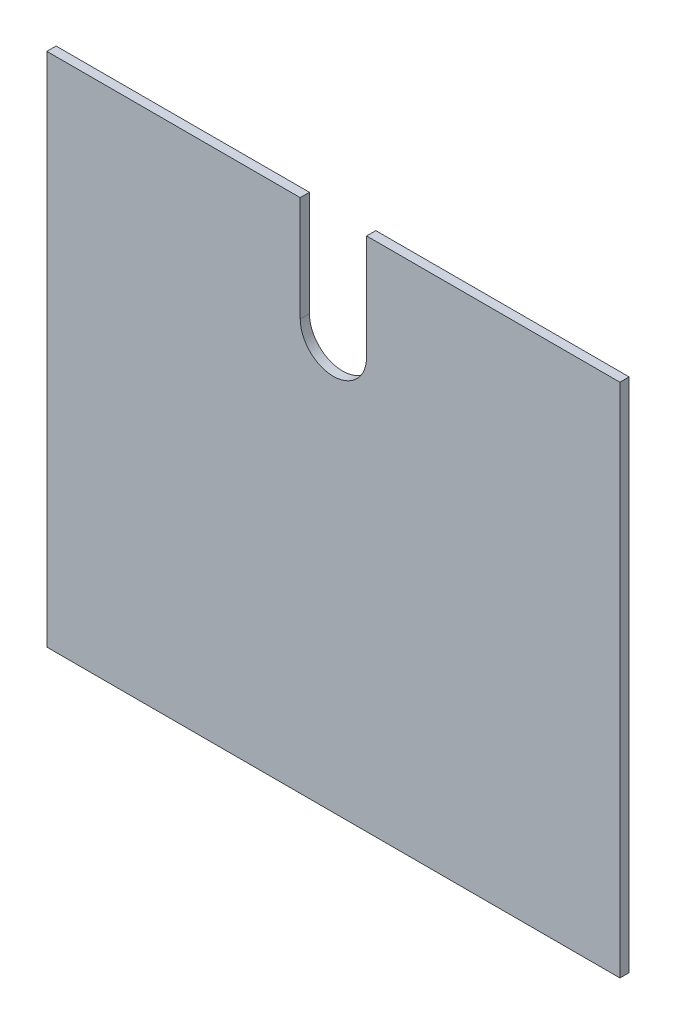
from build123d import *

# Parameters (mm, degrees)
BOSS_EXTRUDE1_DEPTH = 6.35


with BuildPart() as part:
    # Sketch1 → Boss-Extrude1 (new body)
    with BuildSketch(Plane.XY):
        with BuildLine():
            Line((174.625, 355.6), (174.625, 283.21))
            ThreePointArc((174.625, 283.21), (197.485, 260.35), (220.345, 283.21))
            Line((220.345, 283.21), (220.345, 355.6))
            Line((220.345, 355.6), (394.97, 355.6))
            Line((394.97, 355.6), (394.97, 0))
            Line((394.97, 0), (0, 0))
            Line((0, 0), (0, 355.6))
            Line((0, 355.6), (174.625, 355.6))
        make_face()
    extrude(amount=BOSS_EXTRUDE1_DEPTH)


solid = part.part
